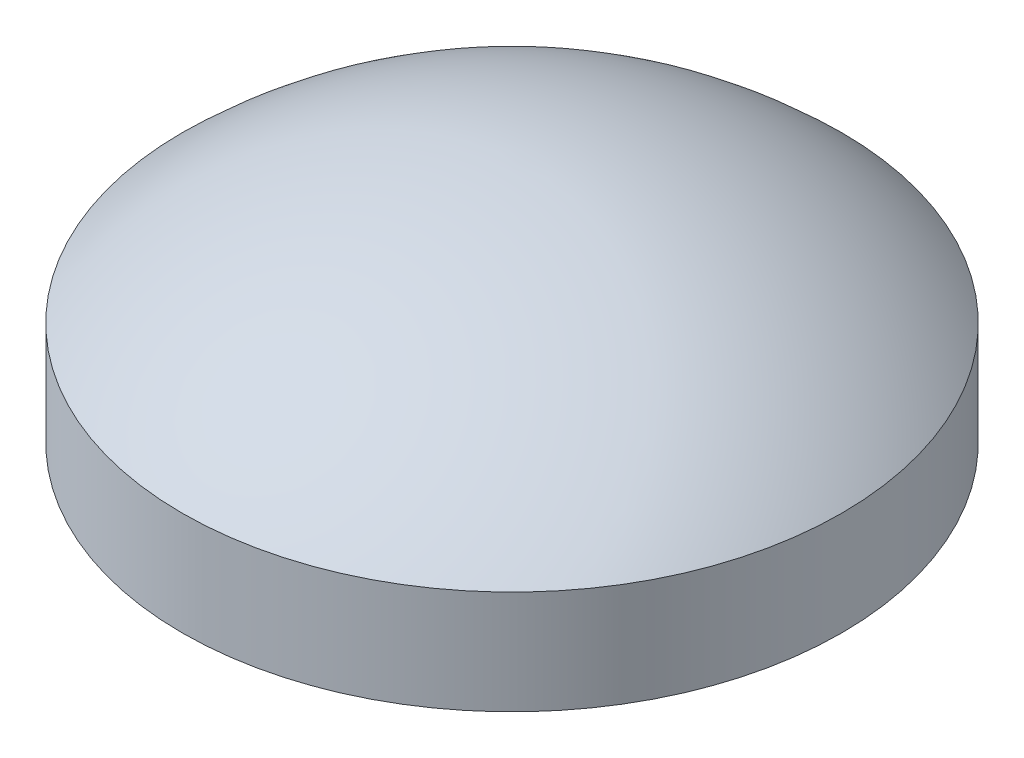
from build123d import *

# Parameters (mm, degrees)
SKETCH3_R           = 39.75
BOSS_EXTRUDE2_DEPTH = 12.5
DOME1_FACE_RADIUS   = 39.75
DOME1_HEIGHT        = 16


with BuildPart() as part:
    # Sketch3 → Boss-Extrude2 (new body)
    with BuildSketch(Plane(origin=(0, 0, 0), x_dir=(-1, 0, 0), z_dir=(0, 1, 0))):
        Circle(SKETCH3_R)
    extrude(amount=BOSS_EXTRUDE2_DEPTH)

    # Dome1: a dome of height H over a round flat face of radius A is a cap of a sphere of radius (A * A + H * H) / (2 * H)
    dome1_r = (DOME1_FACE_RADIUS * DOME1_FACE_RADIUS + DOME1_HEIGHT * DOME1_HEIGHT) / (2 * DOME1_HEIGHT)
    dome1_base = Plane((0, 12.5, 0), z_dir=(0, 1, 0))
    with Locations(dome1_base.offset(DOME1_HEIGHT - dome1_r)):
        dome1_ball = Sphere(dome1_r, mode=Mode.PRIVATE)
    add(split(dome1_ball, bisect_by=dome1_base, keep=Keep.TOP, mode=Mode.PRIVATE))


solid = part.part
